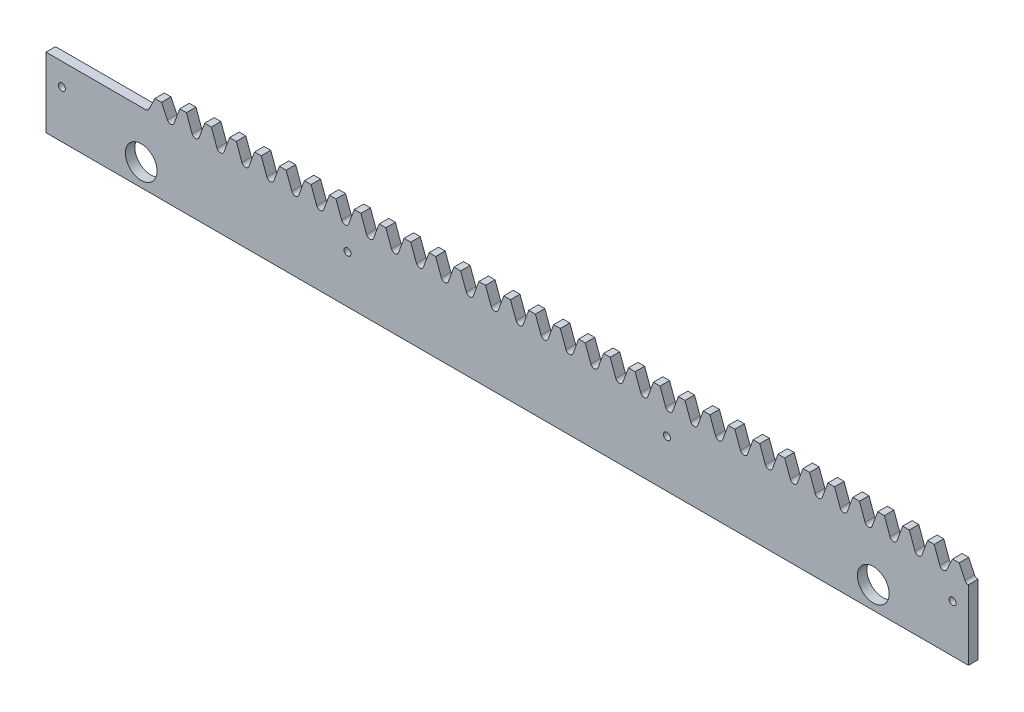
from build123d import *

# Parameters (mm, degrees)
ESQUISSE1_R             = 1.1
EXTRUSION1_DEPTH        = 3
ESQUISSE4_R             = 5
ENL_V_MAT_EXTRU_2_DEPTH = 4


with BuildPart() as part:
    # Esquisse1 → Extrusion1 (new body)
    with BuildSketch(Plane.XY):
        with BuildLine():
            Line((-11.780972452, 22), (19.634954087, 22))
            ThreePointArc((19.634954087, 22), (20.207764851, 22.148388876), (20.636482657, 22.556227657))
            Line((20.636482657, 22.556227657), (22.508375082, 26.5))
            Line((22.508375082, 26.5), (24.615514728, 26.5))
            Line((24.615514728, 26.5), (26.487407153, 22.556227657))
            ThreePointArc((26.487407153, 22.556227657), (26.916124959, 22.148388876), (27.488935722, 22))
            ThreePointArc((27.488935722, 22), (28.165627746, 22.213360175), (28.597563031, 22.776269199))
            Line((28.597563031, 22.776269199), (30.362356717, 27.625))
            Line((30.362356717, 27.625), (32.469496363, 27.625))
            Line((32.469496363, 27.625), (34.234290049, 22.776269199))
            ThreePointArc((34.234290049, 22.776269199), (34.666225334, 22.213360175), (35.342917357, 22))
            ThreePointArc((35.342917357, 22), (36.019609381, 22.213360175), (36.451544666, 22.776269199))
            Line((36.451544666, 22.776269199), (38.216338352, 27.625))
            Line((38.216338352, 27.625), (40.323477998, 27.625))
            Line((40.323477998, 27.625), (42.088271684, 22.776269199))
            ThreePointArc((42.088271684, 22.776269199), (42.520206969, 22.213360175), (43.196898992, 22))
            ThreePointArc((43.196898992, 22), (43.873591016, 22.213360175), (44.305526301, 22.776269199))
            Line((44.305526301, 22.776269199), (46.070319987, 27.625))
            Line((46.070319987, 27.625), (48.177459633, 27.625))
            Line((48.177459633, 27.625), (49.942253319, 22.776269199))
            ThreePointArc((49.942253319, 22.776269199), (50.374188604, 22.213360175), (51.050880627, 22))
            ThreePointArc((51.050880627, 22), (51.727572651, 22.213360175), (52.159507936, 22.776269199))
            Line((52.159507936, 22.776269199), (53.924301622, 27.625))
            Line((53.924301622, 27.625), (56.031441268, 27.625))
            Line((56.031441268, 27.625), (57.796234954, 22.776269199))
            ThreePointArc((57.796234954, 22.776269199), (58.228170239, 22.213360175), (58.904862262, 22))
            ThreePointArc((58.904862262, 22), (59.581554286, 22.213360175), (60.013489571, 22.776269199))
            Line((60.013489571, 22.776269199), (61.778283257, 27.625))
            Line((61.778283257, 27.625), (63.885422903, 27.625))
            Line((63.885422903, 27.625), (65.650216589, 22.776269199))
            ThreePointArc((65.650216589, 22.776269199), (66.082151874, 22.213360175), (66.758843897, 22))
            ThreePointArc((66.758843897, 22), (67.435535921, 22.213360175), (67.867471206, 22.776269199))
            Line((67.867471206, 22.776269199), (69.632264892, 27.625))
            Line((69.632264892, 27.625), (71.739404538, 27.625))
            Line((71.739404538, 27.625), (73.504198224, 22.776269199))
            ThreePointArc((73.504198224, 22.776269199), (73.936133509, 22.213360175), (74.612825532, 22))
            ThreePointArc((74.612825532, 22), (75.289517556, 22.213360175), (75.721452841, 22.776269199))
            Line((75.721452841, 22.776269199), (77.486246527, 27.625))
            Line((77.486246527, 27.625), (79.593386173, 27.625))
            Line((79.593386173, 27.625), (81.358179859, 22.776269199))
            ThreePointArc((81.358179859, 22.776269199), (81.790115144, 22.213360175), (82.466807167, 22))
            ThreePointArc((82.466807167, 22), (83.143499191, 22.213360175), (83.575434476, 22.776269199))
            Line((83.575434476, 22.776269199), (85.340228162, 27.625))
            Line((85.340228162, 27.625), (87.447367808, 27.625))
            Line((87.447367808, 27.625), (89.212161494, 22.776269199))
            ThreePointArc((89.212161494, 22.776269199), (89.644096779, 22.213360175), (90.320788802, 22))
            ThreePointArc((90.320788802, 22), (90.997480826, 22.213360175), (91.429416111, 22.776269199))
            Line((91.429416111, 22.776269199), (93.194209797, 27.625))
            Line((93.194209797, 27.625), (95.301349443, 27.625))
            Line((95.301349443, 27.625), (97.066143129, 22.776269199))
            ThreePointArc((97.066143129, 22.776269199), (97.498078414, 22.213360175), (98.174770437, 22))
            ThreePointArc((98.174770437, 22), (98.851462461, 22.213360175), (99.283397746, 22.776269199))
            Line((99.283397746, 22.776269199), (101.048191432, 27.625))
            Line((101.048191432, 27.625), (103.155331078, 27.625))
            Line((103.155331078, 27.625), (104.920124764, 22.776269199))
            ThreePointArc((104.920124764, 22.776269199), (105.352060049, 22.213360175), (106.028752072, 22))
            ThreePointArc((106.028752072, 22), (106.705444096, 22.213360175), (107.137379381, 22.776269199))
            Line((107.137379381, 22.776269199), (108.902173067, 27.625))
            Line((108.902173067, 27.625), (111.009312713, 27.625))
            Line((111.009312713, 27.625), (112.774106399, 22.776269199))
            ThreePointArc((112.774106399, 22.776269199), (113.206041684, 22.213360175), (113.882733707, 22))
            ThreePointArc((113.882733707, 22), (114.559425731, 22.213360175), (114.991361016, 22.776269199))
            Line((114.991361016, 22.776269199), (116.756154702, 27.625))
            Line((116.756154702, 27.625), (118.863294348, 27.625))
            Line((118.863294348, 27.625), (120.628088034, 22.776269199))
            ThreePointArc((120.628088034, 22.776269199), (121.060023319, 22.213360175), (121.736715342, 22))
            ThreePointArc((121.736715342, 22), (122.413407366, 22.213360175), (122.845342651, 22.776269199))
            Line((122.845342651, 22.776269199), (124.610136337, 27.625))
            Line((124.610136337, 27.625), (126.717275983, 27.625))
            Line((126.717275983, 27.625), (128.482069669, 22.776269199))
            ThreePointArc((128.482069669, 22.776269199), (128.914004954, 22.213360175), (129.590696977, 22))
            ThreePointArc((129.590696977, 22), (130.267389001, 22.213360175), (130.699324286, 22.776269199))
            Line((130.699324286, 22.776269199), (132.464117972, 27.625))
            Line((132.464117972, 27.625), (134.571257618, 27.625))
            Line((134.571257618, 27.625), (136.336051304, 22.776269199))
            ThreePointArc((136.336051304, 22.776269199), (136.767986589, 22.213360175), (137.444678612, 22))
            ThreePointArc((137.444678612, 22), (138.121370636, 22.213360175), (138.553305921, 22.776269199))
            Line((138.553305921, 22.776269199), (140.318099607, 27.625))
            Line((140.318099607, 27.625), (142.425239253, 27.625))
            Line((142.425239253, 27.625), (144.190032939, 22.776269199))
            ThreePointArc((144.190032939, 22.776269199), (144.621968224, 22.213360175), (145.298660247, 22))
            ThreePointArc((145.298660247, 22), (145.975352271, 22.213360175), (146.407287556, 22.776269199))
            Line((146.407287556, 22.776269199), (148.172081242, 27.625))
            Line((148.172081242, 27.625), (150.279220888, 27.625))
            Line((150.279220888, 27.625), (152.044014574, 22.776269199))
            ThreePointArc((152.044014574, 22.776269199), (152.475949859, 22.213360175), (153.152641882, 22))
            ThreePointArc((153.152641882, 22), (153.829333906, 22.213360175), (154.261269191, 22.776269199))
            Line((154.261269191, 22.776269199), (156.026062877, 27.625))
            Line((156.026062877, 27.625), (158.133202523, 27.625))
            Line((158.133202523, 27.625), (159.897996209, 22.776269199))
            ThreePointArc((159.897996209, 22.776269199), (160.329931494, 22.213360175), (161.006623517, 22))
            ThreePointArc((161.006623517, 22), (161.683315541, 22.213360175), (162.115250826, 22.776269199))
            Line((162.115250826, 22.776269199), (163.880044512, 27.625))
            Line((163.880044512, 27.625), (165.987184158, 27.625))
            Line((165.987184158, 27.625), (167.751977844, 22.776269199))
            ThreePointArc((167.751977844, 22.776269199), (168.183913129, 22.213360175), (168.860605152, 22))
            ThreePointArc((168.860605152, 22), (169.537297176, 22.213360175), (169.969232461, 22.776269199))
            Line((169.969232461, 22.776269199), (171.734026147, 27.625))
            Line((171.734026147, 27.625), (173.841165793, 27.625))
            Line((173.841165793, 27.625), (175.605959479, 22.776269199))
            ThreePointArc((175.605959479, 22.776269199), (176.037894764, 22.213360175), (176.714586787, 22))
            ThreePointArc((176.714586787, 22), (177.391278811, 22.213360175), (177.823214096, 22.776269199))
            Line((177.823214096, 22.776269199), (179.588007782, 27.625))
            Line((179.588007782, 27.625), (181.695147428, 27.625))
            Line((181.695147428, 27.625), (183.459941114, 22.776269199))
            ThreePointArc((183.459941114, 22.776269199), (183.891876399, 22.213360175), (184.568568422, 22))
            ThreePointArc((184.568568422, 22), (185.245260446, 22.213360175), (185.677195731, 22.776269199))
            Line((185.677195731, 22.776269199), (187.441989417, 27.625))
            Line((187.441989417, 27.625), (189.549129063, 27.625))
            Line((189.549129063, 27.625), (191.313922749, 22.776269199))
            ThreePointArc((191.313922749, 22.776269199), (191.745858034, 22.213360175), (192.422550057, 22))
            ThreePointArc((192.422550057, 22), (193.099242081, 22.213360175), (193.531177366, 22.776269199))
            Line((193.531177366, 22.776269199), (195.295971052, 27.625))
            Line((195.295971052, 27.625), (197.403110698, 27.625))
            Line((197.403110698, 27.625), (199.167904384, 22.776269199))
            ThreePointArc((199.167904384, 22.776269199), (199.599839669, 22.213360175), (200.276531692, 22))
            ThreePointArc((200.276531692, 22), (200.953223716, 22.213360175), (201.385159001, 22.776269199))
            Line((201.385159001, 22.776269199), (203.149952687, 27.625))
            Line((203.149952687, 27.625), (205.257092333, 27.625))
            Line((205.257092333, 27.625), (207.021886019, 22.776269199))
            ThreePointArc((207.021886019, 22.776269199), (207.453821304, 22.213360175), (208.130513327, 22))
            ThreePointArc((208.130513327, 22), (208.807205351, 22.213360175), (209.239140636, 22.776269199))
            Line((209.239140636, 22.776269199), (211.003934322, 27.625))
            Line((211.003934322, 27.625), (213.111073968, 27.625))
            Line((213.111073968, 27.625), (214.875867654, 22.776269199))
            ThreePointArc((214.875867654, 22.776269199), (215.307802939, 22.213360175), (215.984494962, 22))
            ThreePointArc((215.984494962, 22), (216.661186986, 22.213360175), (217.093122271, 22.776269199))
            Line((217.093122271, 22.776269199), (218.857915957, 27.625))
            Line((218.857915957, 27.625), (220.965055603, 27.625))
            Line((220.965055603, 27.625), (222.729849289, 22.776269199))
            ThreePointArc((222.729849289, 22.776269199), (223.161784574, 22.213360175), (223.838476597, 22))
            ThreePointArc((223.838476597, 22), (224.515168621, 22.213360175), (224.947103906, 22.776269199))
            Line((224.947103906, 22.776269199), (226.711897592, 27.625))
            Line((226.711897592, 27.625), (228.819037238, 27.625))
            Line((228.819037238, 27.625), (230.583830924, 22.776269199))
            ThreePointArc((230.583830924, 22.776269199), (231.015766209, 22.213360175), (231.692458232, 22))
            ThreePointArc((231.692458232, 22), (232.369150256, 22.213360175), (232.801085541, 22.776269199))
            Line((232.801085541, 22.776269199), (234.565879227, 27.625))
            Line((234.565879227, 27.625), (236.673018873, 27.625))
            Line((236.673018873, 27.625), (238.437812559, 22.776269199))
            ThreePointArc((238.437812559, 22.776269199), (238.869747844, 22.213360175), (239.546439867, 22))
            ThreePointArc((239.546439867, 22), (240.223131891, 22.213360175), (240.655067176, 22.776269199))
            Line((240.655067176, 22.776269199), (242.419860862, 27.625))
            Line((242.419860862, 27.625), (244.527000508, 27.625))
            Line((244.527000508, 27.625), (246.291794194, 22.776269199))
            ThreePointArc((246.291794194, 22.776269199), (246.723729479, 22.213360175), (247.400421502, 22))
            ThreePointArc((247.400421502, 22), (248.077113526, 22.213360175), (248.509048811, 22.776269199))
            Line((248.509048811, 22.776269199), (250.273842497, 27.625))
            Line((250.273842497, 27.625), (252.380982143, 27.625))
            Line((252.380982143, 27.625), (254.145775829, 22.776269199))
            ThreePointArc((254.145775829, 22.776269199), (254.577711114, 22.213360175), (255.254403137, 22))
            ThreePointArc((255.254403137, 22), (255.931095161, 22.213360175), (256.363030446, 22.776269199))
            Line((256.363030446, 22.776269199), (258.127824132, 27.625))
            Line((258.127824132, 27.625), (260.234963778, 27.625))
            Line((260.234963778, 27.625), (261.999757464, 22.776269199))
            ThreePointArc((261.999757464, 22.776269199), (262.431692749, 22.213360175), (263.108384772, 22))
            ThreePointArc((263.108384772, 22), (263.785076796, 22.213360175), (264.217012081, 22.776269199))
            Line((264.217012081, 22.776269199), (265.981805767, 27.625))
            Line((265.981805767, 27.625), (268.088945413, 27.625))
            Line((268.088945413, 27.625), (269.853739099, 22.776269199))
            ThreePointArc((269.853739099, 22.776269199), (270.285674384, 22.213360175), (270.962366407, 22))
            ThreePointArc((270.962366407, 22), (271.572652612, 22.17011153), (272.006944946, 22.631389486))
            Line((272.006944946, 22.631389486), (273.835787402, 26.5))
            Line((273.835787402, 26.5), (275.942927048, 26.5))
            Line((275.942927048, 26.5), (277.771769504, 22.631389486))
            ThreePointArc((277.771769504, 22.631389486), (278.231733017, 22.155033667), (278.875867654, 22.001502336))
            Line((278.875867654, 22.001502336), (278.875867654, 0))
            Line((278.875867654, 0), (-11.780972452, 0))
            Line((-11.780972452, 0), (-11.780972452, 22))
        make_face()
        with Locations((183.875867654, 15)):
            Circle(ESQUISSE1_R, mode=Mode.SUBTRACT)
        with Locations((83.219027548, 15)):
            Circle(ESQUISSE1_R, mode=Mode.SUBTRACT)
        with Locations((-6.780972452, 15)):
            Circle(ESQUISSE1_R, mode=Mode.SUBTRACT)
        with Locations((273.875867654, 15)):
            Circle(ESQUISSE1_R, mode=Mode.SUBTRACT)
    extrude(amount=EXTRUSION1_DEPTH)

    # Esquisse4 → Enlèv. mat.-Extru.2 (cut, through all)
    with BuildSketch(Plane.XY.offset(3)):
        with Locations((18.219027547, 7)):
            Circle(ESQUISSE4_R)
        with Locations((248.875867654, 7)):
            Circle(ESQUISSE4_R)
    extrude(amount=-ENL_V_MAT_EXTRU_2_DEPTH, mode=Mode.SUBTRACT)


solid = part.part
